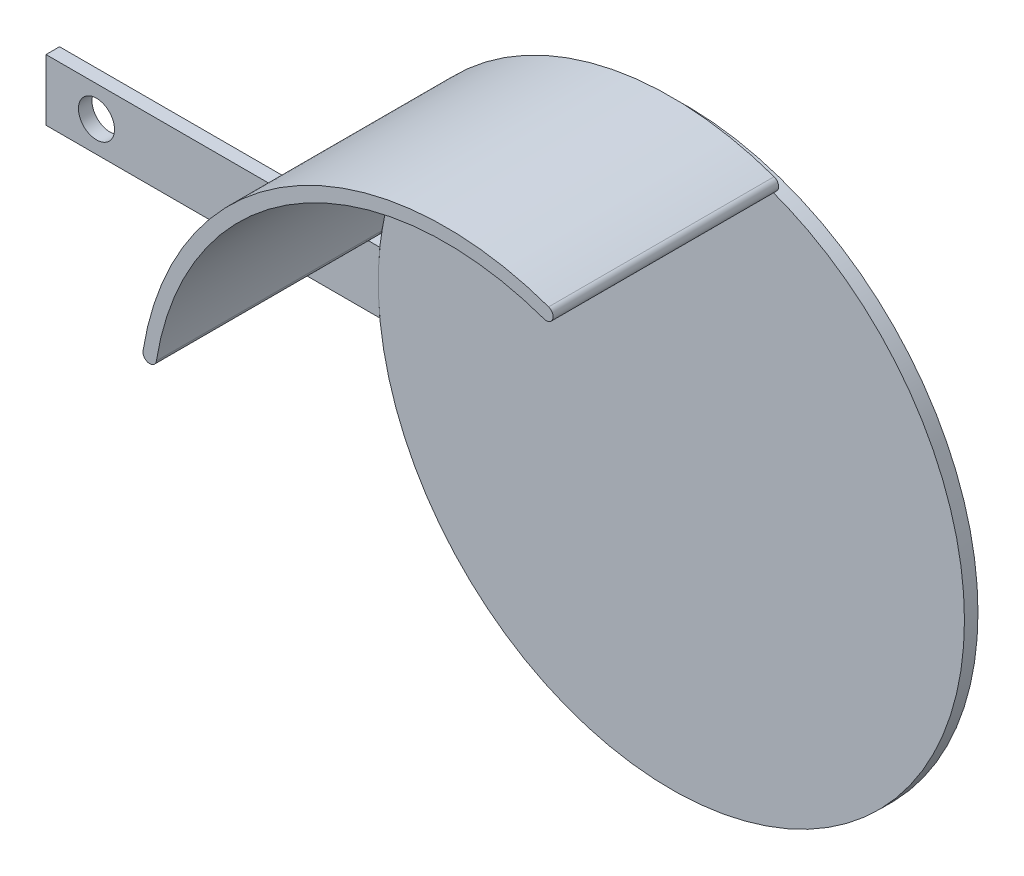
from build123d import *

# Parameters (mm, degrees)
ESQUISSE1_R             = 65
BOSS_EXTRU_1_DEPTH      = 3
BOSS_EXTRU_3_DEPTH      = 3
ESQUISSE4_R             = 4
ENL_V_MAT_EXTRU_1_DEPTH = 3
BOSS_EXTRU_4_DEPTH      = 50


with BuildPart() as part:
    # Esquisse1 → Boss.-Extru.1 (new body)
    with BuildSketch(Plane.XY):
        Circle(ESQUISSE1_R)
    extrude(amount=BOSS_EXTRU_1_DEPTH)


with BuildPart() as body_2:
    # Esquisse3 → Boss.-Extru.3 (new body)
    with BuildSketch(Plane(origin=(0, 0, 0), x_dir=(-1, 0, 0), z_dir=(0, 0, -1))):
        with BuildLine():
            Line((64.643923199, 6.794350112), (138.672522355, 6.794350112))
            Line((138.672522355, 6.794350112), (138.672522355, -6.794350112))
            Line((138.672522355, -6.794350112), (64.643923199, -6.794350112))
            ThreePointArc((64.643923199, -6.794350112), (65, 0), (64.643923199, 6.794350112))
        make_face()
    extrude(amount=-BOSS_EXTRU_3_DEPTH)

    # Esquisse4 → Enlèv. mat.-Extru.1 (cut)
    with BuildSketch(Plane.XY.offset(3)):
        with Locations((-127.477067306, 0)):
            Circle(ESQUISSE4_R)
    extrude(amount=-ENL_V_MAT_EXTRU_1_DEPTH, mode=Mode.SUBTRACT)


with BuildPart() as body_3:
    # Esquisse5 → Boss.-Extru.4 (new body)
    with BuildSketch(Plane.XY.offset(3)):
        with BuildLine():
            ThreePointArc((21.78396045, 61.240991722), (-33.189134732, 55.888114441), (-64.197754074, 10.180784442))
            ThreePointArc((-64.197754074, 10.180784442), (-65.914181886, 8.934238989), (-67.160727339, 10.650666801))
            ThreePointArc((-67.160727339, 10.650666801), (-34.72094095, 58.467565876), (22.789374009, 64.067499032))
            ThreePointArc((22.789374009, 64.067499032), (23.699920885, 62.151538598), (21.78396045, 61.240991722))
        make_face()
    extrude(amount=BOSS_EXTRU_4_DEPTH)


solid = Compound([part.part, body_2.part, body_3.part])
